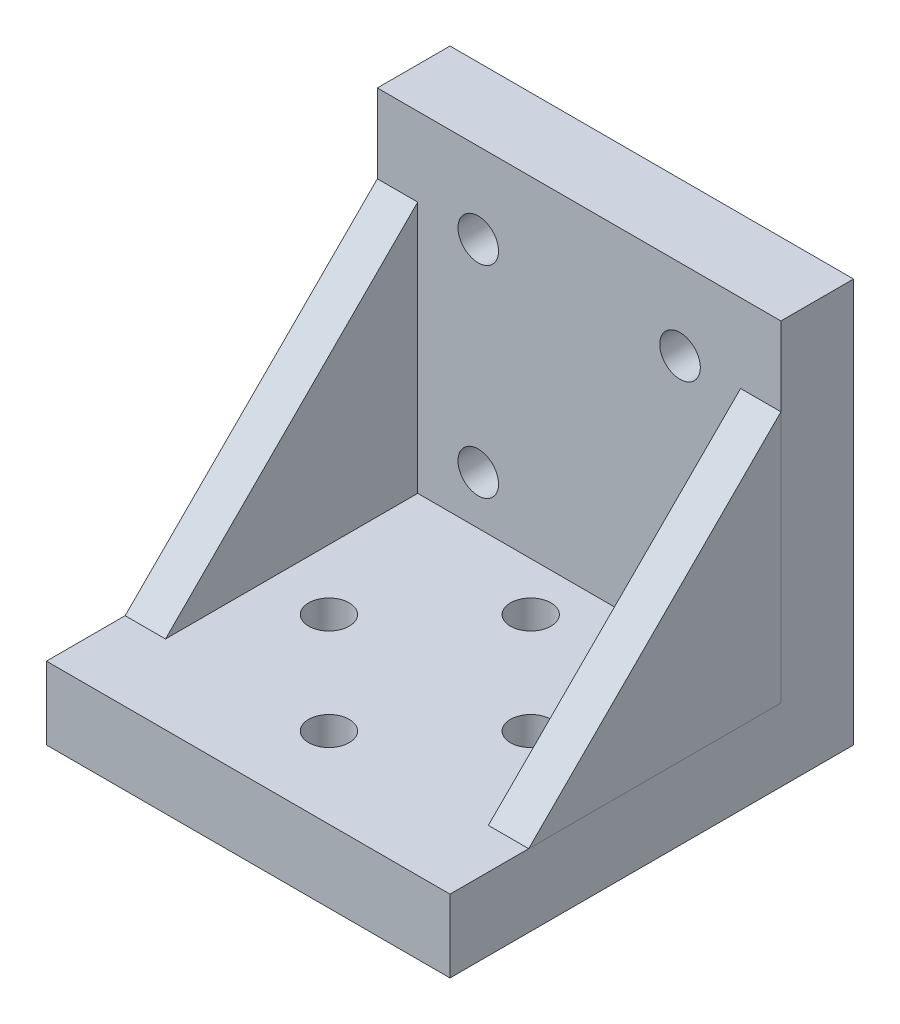
from build123d import *

# Parameters (mm, degrees)
BOSS_EXTRUDE1_DEPTH         = 50.8
F_1_4_20_TAPPED_HOLE2_D     = 5.1054
F_1_4_20_TAPPED_HOLE2_DEPTH = 16.51
F_1_4_20_TAPPED_HOLE2_TIP   = 1.533816902
F_1_4_20_TAPPED_HOLE3_D     = 5.1054
F_1_4_20_TAPPED_HOLE3_DEPTH = 16.51
F_1_4_20_TAPPED_HOLE3_TIP   = 1.533816902
BOSS_EXTRUDE2_DEPTH         = 5.08
BOSS_EXTRUDE3_START         = 50.8
BOSS_EXTRUDE3_DEPTH         = 5.08


with BuildPart() as part:
    # Sketch1 → Boss-Extrude1 (new body)
    with BuildSketch(Plane(origin=(0, 0, 0), x_dir=(0, 0, -1), z_dir=(1, 0, 0))):
        Polygon((0, 0), (-50.8, 0), (-50.8, 9.144), (-9.144, 9.144), (-9.144, 50.8), (0, 50.8), align=None)
    extrude(amount=BOSS_EXTRUDE1_DEPTH)

    # 1_4-20 Tapped Hole2
    with Locations(Plane(origin=(25.4, 0, 40.64), x_dir=(0, 0, -1), z_dir=(0, -1, 0))):
        with Locations((0, 0), (12.7, 12.7), (12.7, -12.7), (25.4, 0)):
            Hole(F_1_4_20_TAPPED_HOLE2_D / 2, depth=F_1_4_20_TAPPED_HOLE2_DEPTH)
            with Locations((0, 0, -(F_1_4_20_TAPPED_HOLE2_DEPTH + F_1_4_20_TAPPED_HOLE2_TIP / 2))):  # 118° drill point
                Cone(0, F_1_4_20_TAPPED_HOLE2_D / 2, F_1_4_20_TAPPED_HOLE2_TIP, mode=Mode.SUBTRACT)

    # 1_4-20 Tapped Hole3
    with Locations(Plane(origin=(12.7, 40.64, 0), x_dir=(-1, 0, 0), z_dir=(0, 0, -1))):
        with Locations((0, 0), (0, -25.4), (-25.4, -25.4), (-25.4, 0)):
            Hole(F_1_4_20_TAPPED_HOLE3_D / 2, depth=F_1_4_20_TAPPED_HOLE3_DEPTH)
            with Locations((0, 0, -(F_1_4_20_TAPPED_HOLE3_DEPTH + F_1_4_20_TAPPED_HOLE3_TIP / 2))):  # 118° drill point
                Cone(0, F_1_4_20_TAPPED_HOLE3_D / 2, F_1_4_20_TAPPED_HOLE3_TIP, mode=Mode.SUBTRACT)


with BuildPart() as body_2:
    # Sketch20 → Boss-Extrude2 (new body)
    with BuildSketch(Plane(origin=(0, 0, 0), x_dir=(0, 0, -1), z_dir=(1, 0, 0))):
        Polygon((-9.144, 9.144), (-9.144, 40.894), (-40.894, 9.144), align=None)
    extrude(amount=BOSS_EXTRUDE2_DEPTH)


with BuildPart() as body_3:
    # Sketch20_2 → Boss-Extrude3 (new body)
    with BuildSketch(Plane(origin=(0, 0, 0), x_dir=(0, 0, -1), z_dir=(1, 0, 0)).offset(BOSS_EXTRUDE3_START)):
        Polygon((-9.144, 9.144), (-9.144, 40.894), (-40.894, 9.144), align=None)
    extrude(amount=-BOSS_EXTRUDE3_DEPTH)


solid = Compound([part.part, body_2.part, body_3.part])
